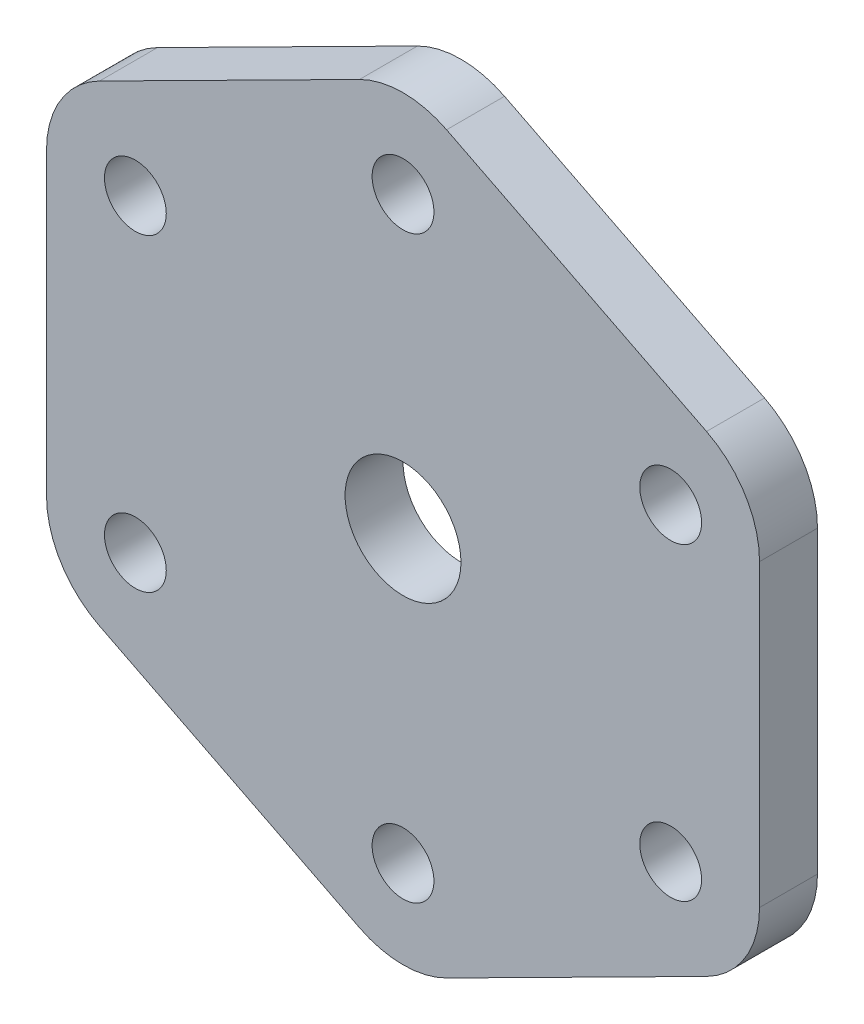
from build123d import *

# Parameters (mm, degrees)
ESBO_O1_R                = 1.6
ESBO_O1_R_2              = 3
RESSALTO_EXTRUS_O1_DEPTH = 3


with BuildPart() as part:
    # Esboço1 → Ressalto-extrusão1 (new body)
    with BuildSketch(Plane(origin=(0, 0, -13), x_dir=(-1, 0, 0), z_dir=(0, 0, -1))):
        with BuildLine():
            Line((-18.456405, 7.753928284), (-18.456405, -7.753928284))
            ThreePointArc((-18.456405, -7.753928284), (-17.715086833, -10.373781151), (-15.710953382, -12.216776208))
            Line((-15.710953382, -12.216776208), (-2.254548382, -19.014703593))
            ThreePointArc((-2.254548382, -19.014703593), (0, -19.551855668), (2.254548382, -19.014703593))
            Line((2.254548382, -19.014703593), (15.710953382, -12.216776208))
            ThreePointArc((15.710953382, -12.216776208), (17.715086833, -10.373781151), (18.456405, -7.753928284))
            Line((18.456405, -7.753928284), (18.456405, 7.753928284))
            ThreePointArc((18.456405, 7.753928284), (17.715086833, 10.373781151), (15.710953382, 12.216776208))
            Line((15.710953382, 12.216776208), (2.254548382, 19.014703593))
            ThreePointArc((2.254548382, 19.014703593), (0, 19.551855668), (-2.254548382, 19.014703593))
            Line((-2.254548382, 19.014703593), (-15.710953382, 12.216776208))
            ThreePointArc((-15.710953382, 12.216776208), (-17.715086833, 10.373781151), (-18.456405, 7.753928284))
        make_face()
        with Locations((13.856405, -8)):
            Circle(ESBO_O1_R, mode=Mode.SUBTRACT)
        with Locations((-13.856405, 8)):
            Circle(ESBO_O1_R, mode=Mode.SUBTRACT)
        with Locations((13.856405, 8)):
            Circle(ESBO_O1_R, mode=Mode.SUBTRACT)
        Circle(ESBO_O1_R_2, mode=Mode.SUBTRACT)
        with Locations((0, 15)):
            Circle(ESBO_O1_R, mode=Mode.SUBTRACT)
        with Locations((-13.856405, -8)):
            Circle(ESBO_O1_R, mode=Mode.SUBTRACT)
        with Locations((0, -15)):
            Circle(ESBO_O1_R, mode=Mode.SUBTRACT)
    extrude(amount=-RESSALTO_EXTRUS_O1_DEPTH)


solid = part.part
